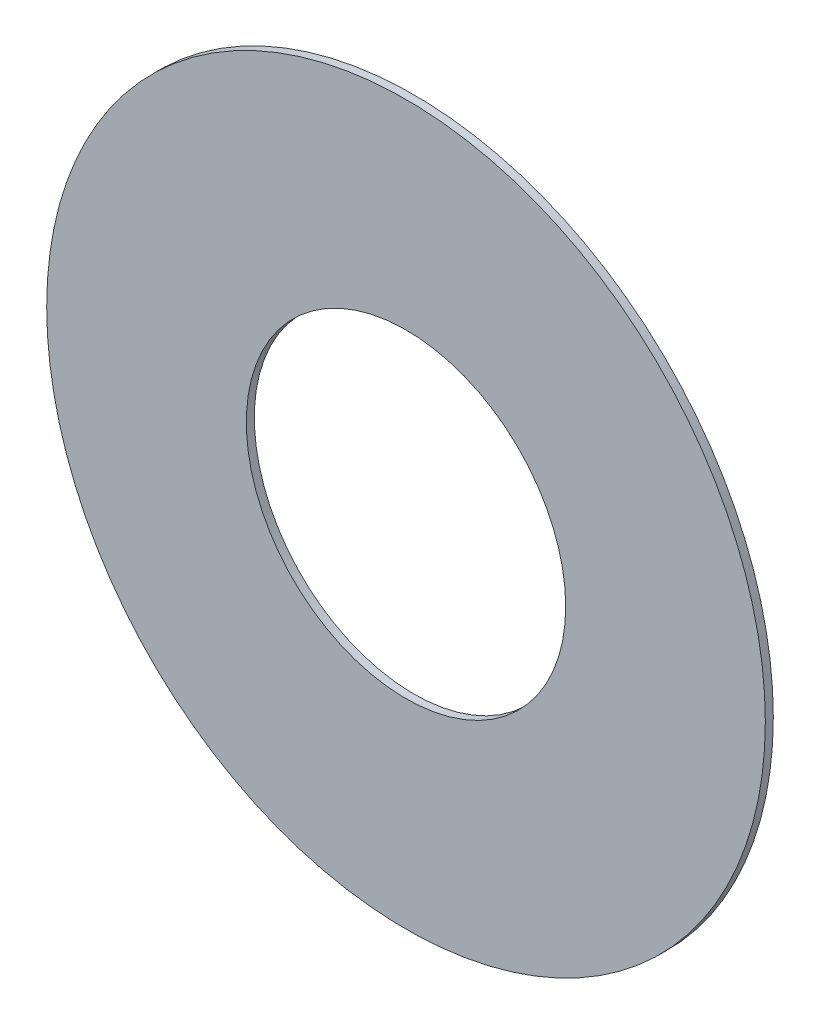
from build123d import *

# Parameters (mm, degrees)
ESQUISSE1_R          = 9
ESQUISSE1_R_2        = 4
BASE_EXTRUSION_DEPTH = 0.2


with BuildPart() as part:
    # Esquisse1 → Base-Extrusion (new body)
    with BuildSketch(Plane.XY):
        Circle(ESQUISSE1_R)
        Circle(ESQUISSE1_R_2, mode=Mode.SUBTRACT)
    extrude(amount=BASE_EXTRUSION_DEPTH)


solid = part.part
